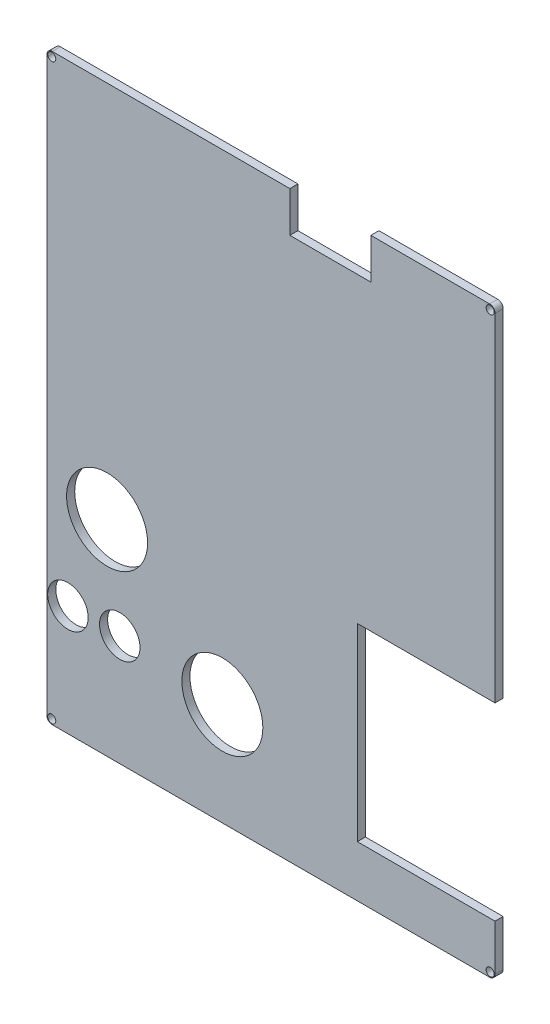
from build123d import *

# Parameters (mm, degrees)
ESQUISSE1_W              = 160
ESQUISSE1_H              = 210
BOSS_EXTRU_1_DEPTH       = 3
CONG_6_R                 = 2
ESQUISSE4_R              = 1.5
ENL_V_MAT_EXTRU_3_DEPTH  = 4
ESQUISSE6_W              = 45
ESQUISSE6_H              = 70
ENL_V_MAT_EXTRU_5_DEPTH  = 4
ESQUISSE7_R              = 15
ENL_V_MAT_EXTRU_6_DEPTH  = 856
ESQUISSE8_R              = 15
ENL_V_MAT_EXTRU_7_DEPTH  = 856
ESQUISSE9_R              = 7.5
ENL_V_MAT_EXTRU_8_DEPTH  = 856
ESQUISSE10_R             = 7.5
ENL_V_MAT_EXTRU_13_DEPTH = 856
ESQUISSE12_W             = 30
ESQUISSE12_H             = 15
ENL_V_MAT_EXTRU_14_DEPTH = 856
ESQUISSE13_W             = 160
ESQUISSE13_H             = 3
BOSS_EXTRU_2_DEPTH       = 3
ESQUISSE14_W             = 3
ESQUISSE14_H             = 213
BOSS_EXTRU_3_DEPTH       = 3
ESQUISSE15_W             = 3
ESQUISSE15_H             = 70
ENL_V_MAT_EXTRU_15_DEPTH = 4
ESQUISSE18_W             = 3
ESQUISSE18_H             = 213
BOSS_EXTRU_4_DEPTH       = 3
ESQUISSE19_W             = 166
ESQUISSE19_H             = 3
BOSS_EXTRU_5_DEPTH       = 3
ESQUISSE20_W             = 3
ESQUISSE20_H             = 70
ENL_V_MAT_EXTRU_16_DEPTH = 3
ESQUISSE21_R             = 1.5
ENL_V_MAT_EXTRU_17_DEPTH = 3
ESQUISSE22_R             = 1.5
ENL_V_MAT_EXTRU_18_DEPTH = 3
ESQUISSE23_R             = 1.5
ENL_V_MAT_EXTRU_19_DEPTH = 3
CONG_7_R                 = 2
CONG_8_R                 = 2
CONG_9_R                 = 2


with BuildPart() as part:
    # Esquisse1 → Boss.-Extru.1 (new body)
    with BuildSketch(Plane.XY):
        with Locations((-86.269341233, 25.410958904)):
            Rectangle(ESQUISSE1_W, ESQUISSE1_H)
    extrude(amount=BOSS_EXTRU_1_DEPTH)

    # Congé6
    cong_6_edges = [part.edges().sort_by_distance(p)[0] for p in [
        (-166.269341233, 130.410958904, 1.5),
    ]]
    fillet(cong_6_edges, radius=CONG_6_R)

    # Esquisse4 → Enlèv. mat.-Extru.3 (cut)
    with BuildSketch(Plane.XY.offset(3)):
        with Locations((-164.469341233, 128.610958904)):
            Circle(ESQUISSE4_R)
    extrude(amount=-ENL_V_MAT_EXTRU_3_DEPTH, mode=Mode.SUBTRACT)

    # Esquisse6 → Enlèv. mat.-Extru.5 (cut)
    with BuildSketch(Plane.XY.offset(3)):
        with Locations((-28.769341233, -31.589041096)):
            Rectangle(ESQUISSE6_W, ESQUISSE6_H)
    extrude(amount=-ENL_V_MAT_EXTRU_5_DEPTH, mode=Mode.SUBTRACT)

    # Esquisse7 → Enlèv. mat.-Extru.6 (cut)
    with BuildSketch(Plane.XY.offset(3)):
        with Locations((-101.269341233, -47.589041096)):
            Circle(ESQUISSE7_R)
    extrude(amount=-ENL_V_MAT_EXTRU_6_DEPTH, mode=Mode.SUBTRACT)

    # Esquisse8 → Enlèv. mat.-Extru.7 (cut)
    with BuildSketch(Plane.XY.offset(3)):
        with Locations((-143.966076441, -9.589041096)):
            Circle(ESQUISSE8_R)
    extrude(amount=-ENL_V_MAT_EXTRU_7_DEPTH, mode=Mode.SUBTRACT)

    # Esquisse9 → Enlèv. mat.-Extru.8 (cut)
    with BuildSketch(Plane.XY.offset(3)):
        with Locations((-139.269341233, -44.589041096)):
            Circle(ESQUISSE9_R)
    extrude(amount=-ENL_V_MAT_EXTRU_8_DEPTH, mode=Mode.SUBTRACT)

    # Esquisse10 → Enlèv. mat.-Extru.13 (cut)
    with BuildSketch(Plane.XY.offset(3)):
        with Locations((-158.469341233, -44.589041096)):
            Circle(ESQUISSE10_R)
    extrude(amount=-ENL_V_MAT_EXTRU_13_DEPTH, mode=Mode.SUBTRACT)

    # Esquisse12 → Enlèv. mat.-Extru.14 (cut)
    with BuildSketch(Plane.XY.offset(3)):
        with Locations((-61.269341233, 122.910958904)):
            Rectangle(ESQUISSE12_W, ESQUISSE12_H)
    extrude(amount=-ENL_V_MAT_EXTRU_14_DEPTH, mode=Mode.SUBTRACT)

    # Esquisse13 → Boss.-Extru.2 (add)
    with BuildSketch(Plane.XZ.offset(79.589041096)):
        with Locations((-86.269341233, 1.5)):
            Rectangle(ESQUISSE13_W, ESQUISSE13_H)
    extrude(amount=BOSS_EXTRU_2_DEPTH)

    # Esquisse14 → Boss.-Extru.3 (add)
    with BuildSketch(Plane(origin=(-6.269341233, 0, 0), x_dir=(0, 0, -1), z_dir=(1, 0, 0))):
        with Locations((-1.5, 23.910958904)):
            Rectangle(ESQUISSE14_W, ESQUISSE14_H)
    extrude(amount=BOSS_EXTRU_3_DEPTH)

    # Esquisse15 → Enlèv. mat.-Extru.15 (cut)
    with BuildSketch(Plane(origin=(-3.269341233, 0, 0), x_dir=(0, 0, -1), z_dir=(1, 0, 0))):
        with Locations((-1.5, -31.589041096)):
            Rectangle(ESQUISSE15_W, ESQUISSE15_H)
    extrude(amount=-ENL_V_MAT_EXTRU_15_DEPTH, mode=Mode.SUBTRACT)

    # Esquisse18 → Boss.-Extru.4 (add)
    with BuildSketch(Plane(origin=(-3.269341233, 0, 0), x_dir=(0, 0, -1), z_dir=(1, 0, 0))):
        with Locations((-1.5, 23.910958904)):
            Rectangle(ESQUISSE18_W, ESQUISSE18_H)
    extrude(amount=BOSS_EXTRU_4_DEPTH)

    # Esquisse19 → Boss.-Extru.5 (add)
    with BuildSketch(Plane(origin=(0, -82.589041096, 0), x_dir=(-1, 0, 0), z_dir=(0, -1, 0))):
        with Locations((83.269341233, -1.5)):
            Rectangle(ESQUISSE19_W, ESQUISSE19_H)
    extrude(amount=BOSS_EXTRU_5_DEPTH)

    # Esquisse20 → Enlèv. mat.-Extru.16 (cut)
    with BuildSketch(Plane(origin=(-0.269341233, 0, 0), x_dir=(0, 0, -1), z_dir=(1, 0, 0))):
        with Locations((-1.5, -31.589041096)):
            Rectangle(ESQUISSE20_W, ESQUISSE20_H)
    extrude(amount=-ENL_V_MAT_EXTRU_16_DEPTH, mode=Mode.SUBTRACT)

    # Esquisse21 → Enlèv. mat.-Extru.17 (cut)
    with BuildSketch(Plane.XY.offset(3)):
        with Locations((-2.069341233, 128.610958904)):
            Circle(ESQUISSE21_R)
    extrude(amount=-ENL_V_MAT_EXTRU_17_DEPTH, mode=Mode.SUBTRACT)

    # Esquisse22 → Enlèv. mat.-Extru.18 (cut)
    with BuildSketch(Plane.XY.offset(3)):
        with Locations((-2.069341233, -83.789041096)):
            Circle(ESQUISSE22_R)
    extrude(amount=-ENL_V_MAT_EXTRU_18_DEPTH, mode=Mode.SUBTRACT)

    # Esquisse23 → Enlèv. mat.-Extru.19 (cut)
    with BuildSketch(Plane.XY.offset(3)):
        with Locations((-164.469341233, -83.789041096)):
            Circle(ESQUISSE23_R)
    extrude(amount=-ENL_V_MAT_EXTRU_19_DEPTH, mode=Mode.SUBTRACT)

    # Congé7
    cong_7_edges = [part.edges().sort_by_distance(p)[0] for p in [
        (-0.269341233, -85.589041096, 1.5),
    ]]
    fillet(cong_7_edges, radius=CONG_7_R)

    # Congé8
    cong_8_edges = [part.edges().sort_by_distance(p)[0] for p in [
        (-0.269341233, 130.410958904, 1.5),
    ]]
    fillet(cong_8_edges, radius=CONG_8_R)

    # Congé9
    cong_9_edges = [part.edges().sort_by_distance(p)[0] for p in [
        (-166.269341233, -85.589041096, 1.5),
    ]]
    fillet(cong_9_edges, radius=CONG_9_R)


solid = part.part
